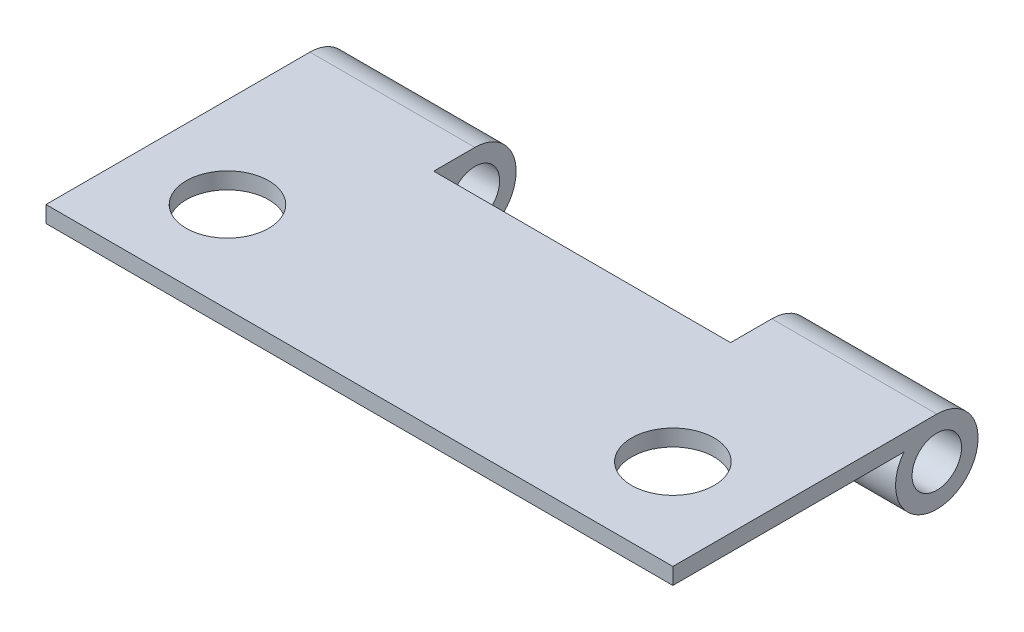
from build123d import *

# Parameters (mm, degrees)
SKETCH3_R           = 1.5
BOSS_EXTRUDE2_DEPTH = 38
SKETCH6_W           = 18
SKETCH6_H           = 5
CUT_EXTRUDE1_DEPTH  = 6
SKETCH7_R           = 2.5
CUT_EXTRUDE2_DEPTH  = 10


with BuildPart() as part:
    # Sketch3 → Boss-Extrude2 (new body)
    with BuildSketch(Plane(origin=(0, 0, 0), x_dir=(0, 0, -1), z_dir=(1, 0, 0))):
        with BuildLine():
            Line((16, 1), (0, 1))
            Line((0, 1), (0, 0))
            Line((0, 0), (14, 0))
            ThreePointArc((14, 0), (17.118033989, -3.736067977), (16, 1))
        make_face()
        with Locations((16, -1.5)):
            Circle(SKETCH3_R, mode=Mode.SUBTRACT)
    extrude(amount=BOSS_EXTRUDE2_DEPTH)

    # Sketch6 → Cut-Extrude1 (cut, through all)
    with BuildSketch(Plane(origin=(0, 1, 0), x_dir=(1, 0, 0), z_dir=(0, 1, 0))):
        with Locations((19, 16)):
            Rectangle(SKETCH6_W, SKETCH6_H)
    extrude(amount=-CUT_EXTRUDE1_DEPTH, mode=Mode.SUBTRACT)

    # Sketch7 → Cut-Extrude2 (cut)
    with BuildSketch(Plane(origin=(0, 1, 0), x_dir=(1, 0, 0), z_dir=(0, 1, 0))):
        with Locations((5.5, 5.5)):
            Circle(SKETCH7_R)
        with Locations((32.5, 5.5)):
            Circle(SKETCH7_R)
    extrude(amount=-CUT_EXTRUDE2_DEPTH, mode=Mode.SUBTRACT)


solid = part.part
